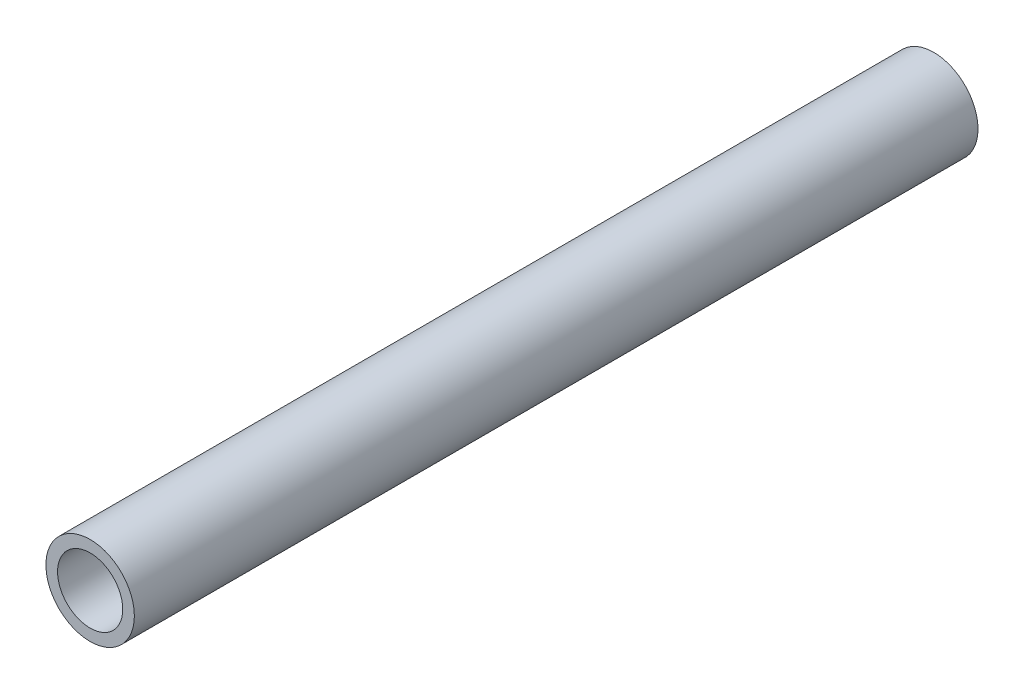
from build123d import *

# Parameters (mm, degrees)
SKETCH1_R           = 4.826
SKETCH1_R_2         = 3.556
BOSS_EXTRUDE1_DEPTH = 92.075


with BuildPart() as part:
    # Sketch1 → Boss-Extrude1 (new body)
    with BuildSketch(Plane.XY):
        Circle(SKETCH1_R)
        Circle(SKETCH1_R_2, mode=Mode.SUBTRACT)
    extrude(amount=BOSS_EXTRUDE1_DEPTH)


solid = part.part
